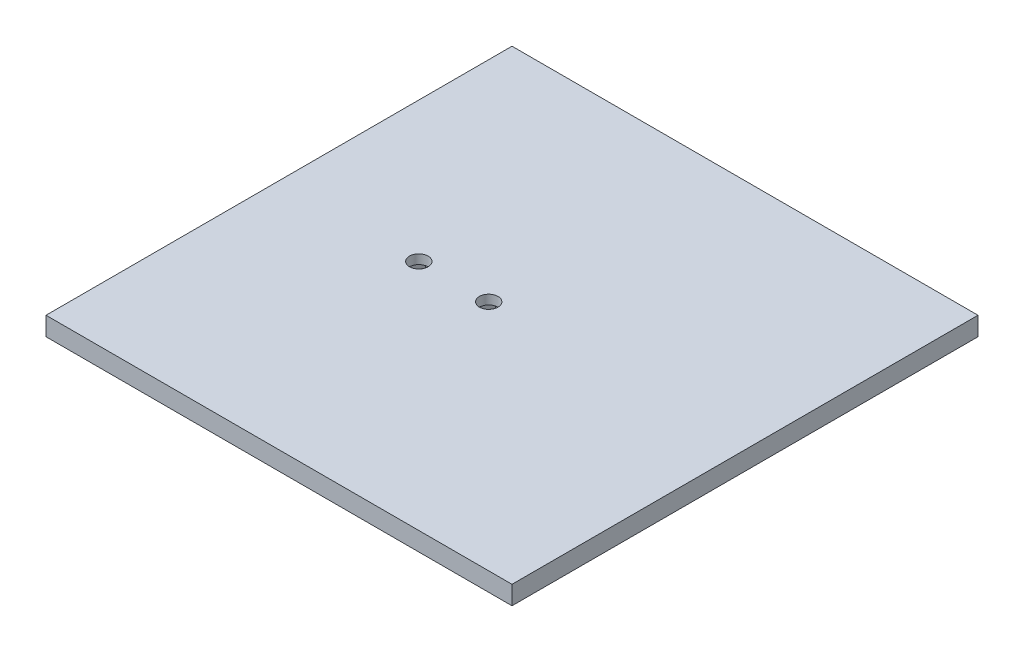
from build123d import *

# Parameters (mm, degrees)
SKETCH1_W           = 100
SKETCH1_H           = 100
BOSS_EXTRUDE1_DEPTH = 4
SKETCH3_R           = 2
CUT_EXTRUDE1_DEPTH  = 2
CUT_EXTRUDE2_DEPTH  = 2


with BuildPart() as part:
    # Sketch1 → Boss-Extrude1 (new body)
    with BuildSketch(Plane(origin=(0, 0, 0), x_dir=(1, 0, 0), z_dir=(0, 1, 0))):
        with Locations((15.12345679, -26.466049383)):
            Rectangle(SKETCH1_W, SKETCH1_H)
    extrude(amount=BOSS_EXTRUDE1_DEPTH)

    # Sketch3 → Cut-Extrude1 (cut)
    with BuildSketch(Plane(origin=(0, 4, 0), x_dir=(1, 0, 0), z_dir=(0, 1, 0))):
        with Locations((-4.87654321, -26.466049383)):
            Circle(SKETCH3_R)
        with Locations((10.12345679, -26.466049383)):
            Circle(SKETCH3_R)
    extrude(amount=-CUT_EXTRUDE1_DEPTH, mode=Mode.SUBTRACT)

    # Sketch5 → Cut-Extrude2 (cut)
    with BuildSketch(Plane.XZ):
        Polygon((-0.835091326, 26.466049383), (-2.855817268, 29.966049383), (-6.897269152, 29.966049383), (-8.917995094, 26.466049383), (-6.897269152, 22.966049383), (-2.855817268, 22.966049383), align=None)
        Polygon((14.164908674, 26.466049383), (12.144182732, 29.966049383), (8.102730848, 29.966049383), (6.082004906, 26.466049383), (8.102730848, 22.966049383), (12.144182732, 22.966049383), align=None)
    extrude(amount=-CUT_EXTRUDE2_DEPTH, mode=Mode.SUBTRACT)


solid = part.part
